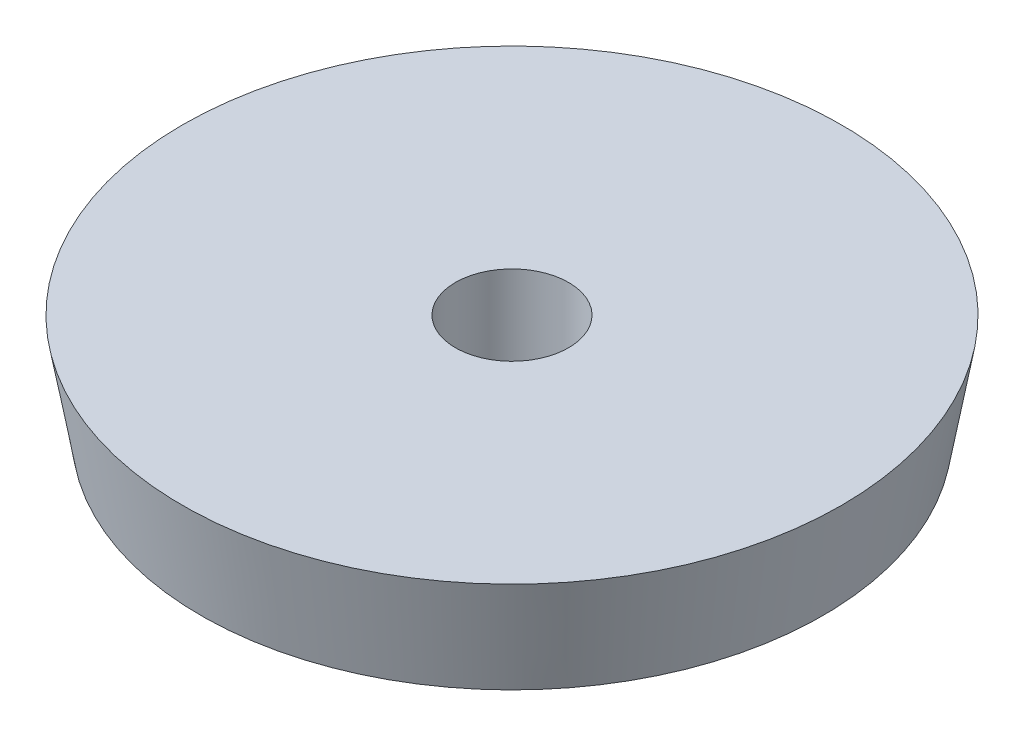
from build123d import *

# Parameters (mm, degrees)
SKETCH2_R          = 34.3535
CUT_EXTRUDE1_DEPTH = 64.5


with BuildPart() as part:
    # Sketch1 → Revolve1 (revolve)
    with BuildSketch(Plane.XY):
        Polygon((0, 0), (0, -63.5), (188.803236725, -63.5), (200, 0), align=None)
    revolve(axis=Axis((0, 0, 0), (0, -1, 0)))

    # Sketch2 → Cut-Extrude1 (cut, through all)
    with BuildSketch(Plane(origin=(0, 0, 0), x_dir=(1, 0, 0), z_dir=(0, 1, 0))):
        Circle(SKETCH2_R)
    extrude(amount=-CUT_EXTRUDE1_DEPTH, mode=Mode.SUBTRACT)


solid = part.part
